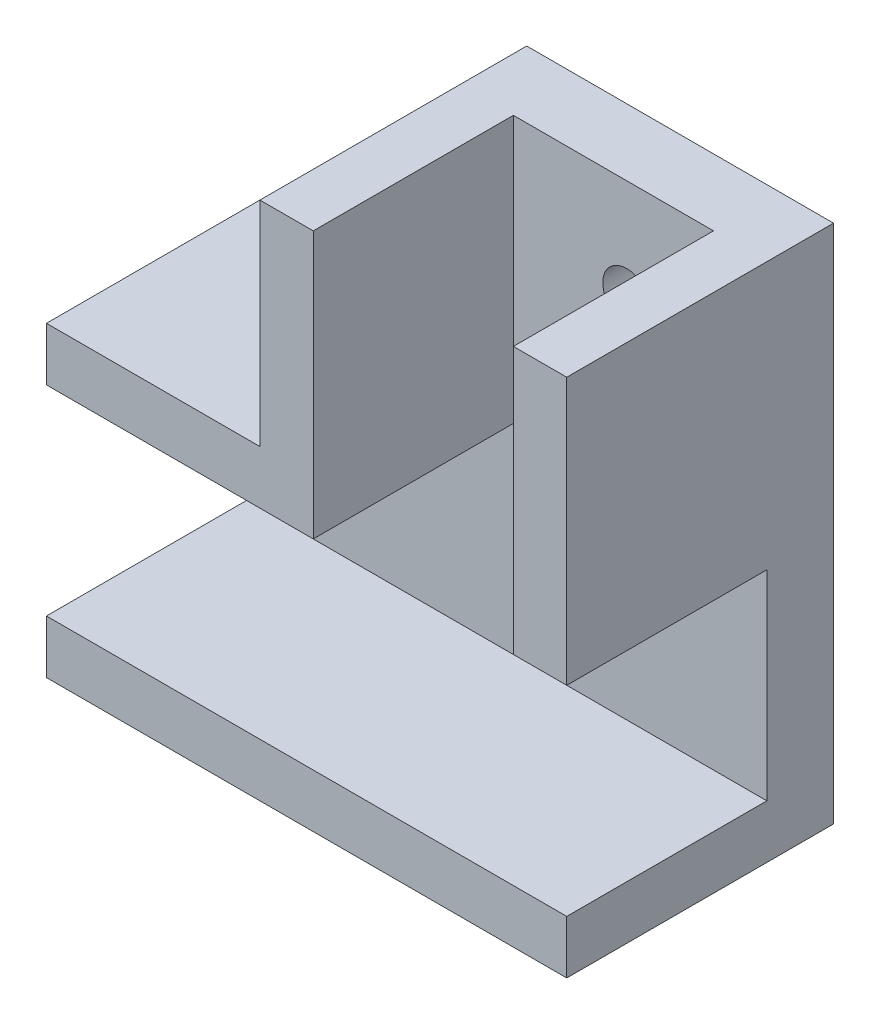
from build123d import *

# Parameters (mm, degrees)
BOSS_EXTRUDE1_DEPTH     = 5
BOSS_EXTRUDE2_DEPTH     = 20
SKETCH4_W               = 35
SKETCH4_H               = 4
BOSS_EXTRUDE3_DEPTH     = 20
SKETCH6_R               = 1.8
CUT_EXTRUDE3_DEPTH      = 6
SKETCH7_W               = 4
SKETCH7_H               = 39
BOSS_EXTRUDE4_DEPTH     = 20
SKETCH8_W               = 15
SKETCH8_H               = 15
CUT_EXTRUDE4_DEPTH      = 1
CUT_EXTRUDE4_DEPTH_BACK = 40


with BuildPart() as part:
    # Sketch1 → Boss-Extrude1 (new body)
    with BuildSketch(Plane.XY):
        Polygon((-20.68627451, -4.264705882), (-0.68627451, -4.264705882), (-0.68627451, 15.735294118), (14.31372549, 15.735294118), (14.31372549, -4.264705882), (14.31372549, -19.264705882), (-20.68627451, -19.264705882), align=None)
    extrude(amount=BOSS_EXTRUDE1_DEPTH)

    # Sketch2 → Boss-Extrude2 (add)
    with BuildSketch(Plane(origin=(0, 0, 0), x_dir=(-1, 0, 0), z_dir=(0, 0, -1))):
        Polygon((0.68627451, 15.735294118), (4.68627451, 15.735294118), (4.68627451, -0.264705882), (6.079970528, -0.264705882), (20.68627451, -0.264705882), (20.68627451, -4.264705882), (0.68627451, -4.264705882), align=None)
    extrude(amount=-BOSS_EXTRUDE2_DEPTH)

    # Sketch4 → Boss-Extrude3 (add)
    with BuildSketch(Plane(origin=(0, 0, 0), x_dir=(-1, 0, 0), z_dir=(0, 0, -1))):
        with Locations((3.18627451, -21.264705882)):
            Rectangle(SKETCH4_W, SKETCH4_H)
    extrude(amount=-BOSS_EXTRUDE3_DEPTH)

    # Sketch6 → Cut-Extrude3 (cut, through all)
    with BuildSketch(Plane.XY.offset(5)):
        with Locations((7.81372549, 8.235294118)):
            Circle(SKETCH6_R)
        with Locations((-13.18627451, -11.764705882)):
            Circle(SKETCH6_R)
    extrude(amount=-CUT_EXTRUDE3_DEPTH, mode=Mode.SUBTRACT)

    # Sketch7 → Boss-Extrude4 (add)
    with BuildSketch(Plane(origin=(0, 0, 0), x_dir=(-1, 0, 0), z_dir=(0, 0, -1))):
        with Locations((-16.31372549, -3.764705882)):
            Rectangle(SKETCH7_W, SKETCH7_H)
    extrude(amount=-BOSS_EXTRUDE4_DEPTH)

    # Sketch8 → Cut-Extrude4 (cut, two sides)
    with BuildSketch(Plane.ZY.offset(20.68627451)) as cut_extrude4_sk:
        with Locations((12.5, -11.764705882)):
            Rectangle(SKETCH8_W, SKETCH8_H)
    extrude(amount=CUT_EXTRUDE4_DEPTH, mode=Mode.SUBTRACT)
    extrude(cut_extrude4_sk.sketch, amount=-CUT_EXTRUDE4_DEPTH_BACK, mode=Mode.SUBTRACT)


solid = part.part
